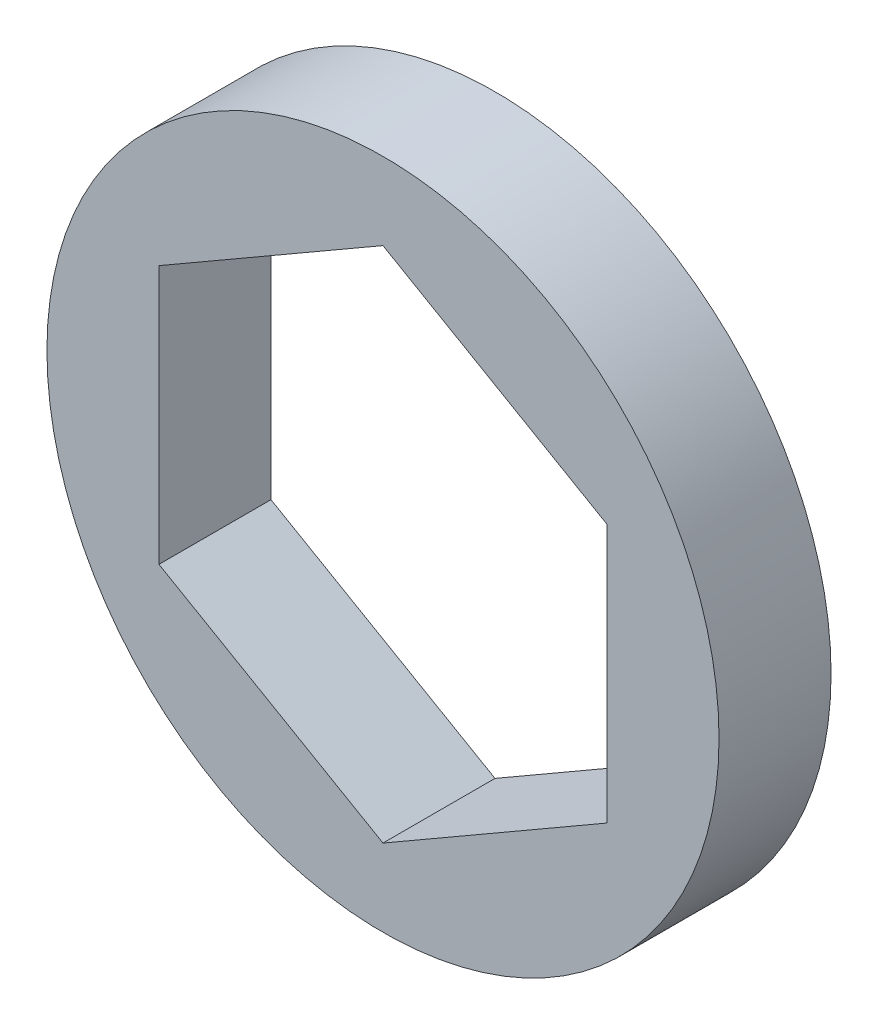
from build123d import *

# Parameters (mm, degrees)
SKETCH2_R           = 9.525
BOSS_EXTRUDE1_DEPTH = 3.175


with BuildPart() as part:
    # Sketch2 → Boss-Extrude1 (new body)
    with BuildSketch(Plane.XY):
        Circle(SKETCH2_R)
        Polygon((0, 7.332348419), (-6.35, 3.666174209), (-6.35, -3.666174209), (0, -7.332348419), (6.35, -3.666174209), (6.35, 3.666174209), align=None, mode=Mode.SUBTRACT)
    extrude(amount=BOSS_EXTRUDE1_DEPTH)


solid = part.part
